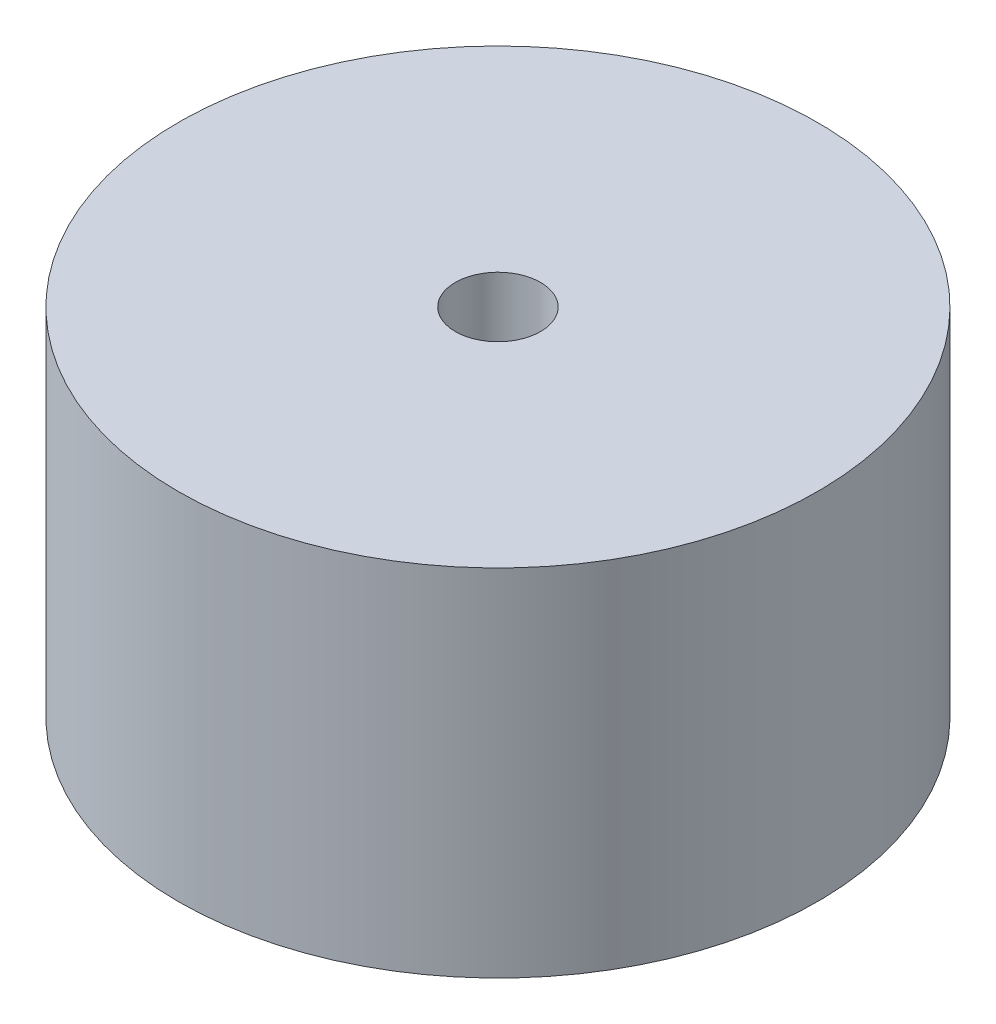
from build123d import *

# Parameters (mm, degrees)
SKETCH1_R           = 45
BOSS_EXTRUDE1_DEPTH = 50


with BuildPart() as part:
    # Sketch1 → Boss-Extrude1 (new body)
    with BuildSketch(Plane(origin=(0, 0, 0), x_dir=(1, 0, 0), z_dir=(0, 1, 0))):
        Circle(SKETCH1_R)
    extrude(amount=BOSS_EXTRUDE1_DEPTH)

    # Sketch2 → Cut-Revolve1 (revolve, cut)
    with BuildSketch(Plane(origin=(0, 0, 0), x_dir=(0, 0, -1), z_dir=(1, 0, 0))):
        Polygon((0, 50), (0, 0), (-40, 0), (-40, 10), (-37, 10), (-6, 41), (-6, 50), align=None)
    revolve(axis=Axis((0, 50, 0), (0, -1, 0)), mode=Mode.SUBTRACT)


solid = part.part
